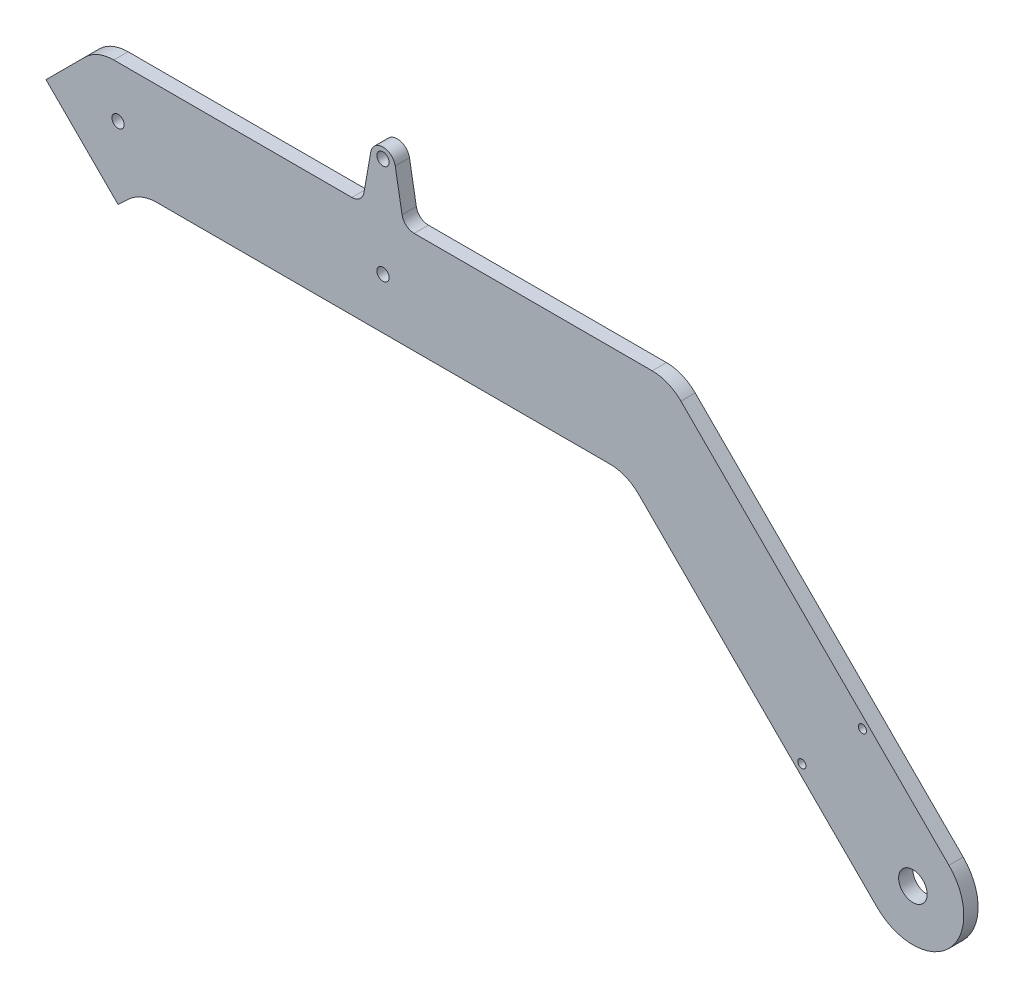
from build123d import *

# Parameters (mm, degrees)
SKETCH3_R           = 3.5
SKETCH3_R_2         = 1.5
BOSS_EXTRUDE1_DEPTH = 3.5
FILLET1_R           = 10
FILLET2_R           = 3
SKETCH4_R           = 1
CUT_EXTRUDE1_DEPTH  = 10


with BuildPart() as part:
    # Sketch3 → Boss-Extrude1 (new body)
    with BuildSketch(Plane.XY):
        with BuildLine():
            Line((5.559439508, 52.5), (0, 47.32233047))
            Line((0, 47.32233047), (-17.67766953, 65))
            Line((-17.67766953, 65), (-5.17766953, 77.5))
            Line((-5.17766953, 77.5), (59.884076231, 77.5))
            Line((59.884076231, 77.5), (62, 89.5))
            ThreePointArc((62, 89.5), (65, 92.017298894), (68, 89.5))
            Line((68, 89.5), (70.115923769, 77.5))
            Line((70.115923769, 77.5), (135.17766953, 77.5))
            Line((135.17766953, 77.5), (203.838834765, 8.838834765))
            ThreePointArc((203.838834765, 8.838834765), (203.838834765, -8.838834765), (186.161165235, -8.838834765))
            Line((186.161165235, -8.838834765), (124.82233047, 52.5))
            Line((124.82233047, 52.5), (5.559439508, 52.5))
        make_face()
        with Locations((195, 0)):
            Circle(SKETCH3_R, mode=Mode.SUBTRACT)
        with Locations((0, 65)):
            Circle(SKETCH3_R_2, mode=Mode.SUBTRACT)
        with Locations((65, 65)):
            Circle(SKETCH3_R_2, mode=Mode.SUBTRACT)
        with Locations((65, 89.5)):
            Circle(SKETCH3_R_2, mode=Mode.SUBTRACT)
    extrude(amount=BOSS_EXTRUDE1_DEPTH)

    # Fillet1
    fillet1_edges = [part.edges().sort_by_distance(p)[0] for p in [
        (5.559439508, 52.5, 1.75),
        (-5.17766953, 77.5, 1.75),
        (135.17766953, 77.5, 1.75),
        (124.82233047, 52.5, 1.75),
    ]]
    fillet(fillet1_edges, radius=FILLET1_R)

    # Fillet2
    fillet2_edges = [part.edges().sort_by_distance(p)[0] for p in [
        (59.884076231, 77.5, 1.75),
        (70.115923769, 77.5, 1.75),
    ]]
    fillet(fillet2_edges, radius=FILLET2_R)

    # Sketch4 → Cut-Extrude1 (cut)
    with BuildSketch(Plane(origin=(0, 0, 0), x_dir=(-1, 0, 0), z_dir=(0, 0, -1))):
        with Locations((-167.776388924, 12.374368671)):
            Circle(SKETCH4_R)
        with Locations((-182.625631329, 27.223611076)):
            Circle(SKETCH4_R)
    extrude(amount=-CUT_EXTRUDE1_DEPTH, mode=Mode.SUBTRACT)


solid = part.part
